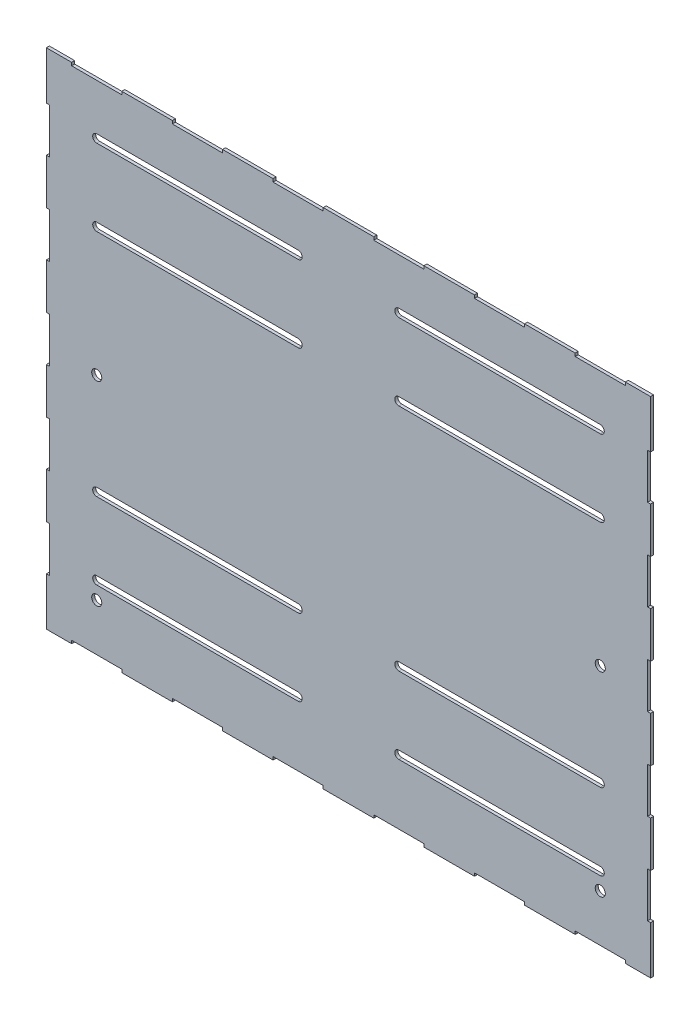
from build123d import *

# Parameters (mm, degrees)
CROQUIS1_W              = 600
CROQUIS1_H              = 500
CROQUIS1_R              = 5
SALIENTE_EXTRUIR1_DEPTH = 3
CROQUIS5_W              = 49.8
CROQUIS5_H              = 3
CROQUIS5_W_2            = 3
CROQUIS5_H_2            = 44.8
CORTAR_EXTRUIR2_DEPTH   = 4


with BuildPart() as part:
    # Croquis1 → Saliente-Extruir1 (new body)
    with BuildSketch(Plane.XY):
        Rectangle(CROQUIS1_W, CROQUIS1_H)
        with Locations((-250, -200)):
            Circle(CROQUIS1_R, mode=Mode.SUBTRACT)
        with Locations((-250, -6.5)):
            Circle(CROQUIS1_R, mode=Mode.SUBTRACT)
        with Locations((250, -200)):
            Circle(CROQUIS1_R, mode=Mode.SUBTRACT)
        with Locations((250, -6.5)):
            Circle(CROQUIS1_R, mode=Mode.SUBTRACT)
        with BuildLine():
            Line((-250, 201), (-50, 201))
            ThreePointArc((-50, 201), (-46, 197), (-50, 193))
            Line((-50, 193), (-250, 193))
            ThreePointArc((-250, 193), (-254, 197), (-250, 201))
        make_face(mode=Mode.SUBTRACT)
        with BuildLine():
            Line((-250, 117), (-50, 117))
            ThreePointArc((-50, 117), (-46, 121), (-50, 125))
            Line((-50, 125), (-250, 125))
            ThreePointArc((-250, 125), (-254, 121), (-250, 117))
        make_face(mode=Mode.SUBTRACT)
        with BuildLine():
            Line((-250, -111), (-50, -111))
            ThreePointArc((-50, -111), (-46, -107), (-50, -103))
            Line((-50, -103), (-250, -103))
            ThreePointArc((-250, -103), (-254, -107), (-250, -111))
        make_face(mode=Mode.SUBTRACT)
        with BuildLine():
            Line((-250, -187), (-50, -187))
            ThreePointArc((-50, -187), (-46, -183), (-50, -179))
            Line((-50, -179), (-250, -179))
            ThreePointArc((-250, -179), (-254, -183), (-250, -187))
        make_face(mode=Mode.SUBTRACT)
        with BuildLine():
            Line((250, -103), (50, -103))
            ThreePointArc((50, -103), (46, -107), (50, -111))
            Line((50, -111), (250, -111))
            ThreePointArc((250, -111), (254, -107), (250, -103))
        make_face(mode=Mode.SUBTRACT)
        with BuildLine():
            Line((250, -179), (50, -179))
            ThreePointArc((50, -179), (46, -183), (50, -187))
            Line((50, -187), (250, -187))
            ThreePointArc((250, -187), (254, -183), (250, -179))
        make_face(mode=Mode.SUBTRACT)
        with BuildLine():
            Line((250, 201), (50, 201))
            ThreePointArc((50, 201), (46, 197), (50, 193))
            Line((50, 193), (250, 193))
            ThreePointArc((250, 193), (254, 197), (250, 201))
        make_face(mode=Mode.SUBTRACT)
        with BuildLine():
            Line((250, 125), (50, 125))
            ThreePointArc((50, 125), (46, 121), (50, 117))
            Line((50, 117), (250, 117))
            ThreePointArc((250, 117), (254, 121), (250, 125))
        make_face(mode=Mode.SUBTRACT)
    extrude(amount=SALIENTE_EXTRUIR1_DEPTH)

    # Croquis5 → Cortar-Extruir2 (cut, through all)
    with BuildSketch(Plane(origin=(0, 0, 0), x_dir=(-1, 0, 0), z_dir=(0, 0, -1))):
        with Locations((150, 248.5)):
            Rectangle(CROQUIS5_W, CROQUIS5_H)
        with Locations((50, 248.5)):
            Rectangle(CROQUIS5_W, CROQUIS5_H)
        with Locations((250, 248.5)):
            Rectangle(CROQUIS5_W, CROQUIS5_H)
        with Locations((-50, 248.5)):
            Rectangle(CROQUIS5_W, CROQUIS5_H)
        with Locations((-150, 248.5)):
            Rectangle(CROQUIS5_W, CROQUIS5_H)
        with Locations((298.5, 180)):
            Rectangle(CROQUIS5_W_2, CROQUIS5_H_2)
        with Locations((-250, 248.5)):
            Rectangle(CROQUIS5_W, CROQUIS5_H)
        with Locations((298.5, 90)):
            Rectangle(CROQUIS5_W_2, CROQUIS5_H_2)
        with Locations((298.5, 0)):
            Rectangle(CROQUIS5_W_2, CROQUIS5_H_2)
        with Locations((298.5, -90)):
            Rectangle(CROQUIS5_W_2, CROQUIS5_H_2)
        with Locations((298.5, -180)):
            Rectangle(CROQUIS5_W_2, CROQUIS5_H_2)
        with Locations((-250, -248.5)):
            Rectangle(CROQUIS5_W, CROQUIS5_H)
        with Locations((-150, -248.5)):
            Rectangle(CROQUIS5_W, CROQUIS5_H)
        with Locations((-50, -248.5)):
            Rectangle(CROQUIS5_W, CROQUIS5_H)
        with Locations((50, -248.5)):
            Rectangle(CROQUIS5_W, CROQUIS5_H)
        with Locations((250, -248.5)):
            Rectangle(CROQUIS5_W, CROQUIS5_H)
        with Locations((150, -248.5)):
            Rectangle(CROQUIS5_W, CROQUIS5_H)
        with Locations((-298.5, -180)):
            Rectangle(CROQUIS5_W_2, CROQUIS5_H_2)
        with Locations((-298.5, -90)):
            Rectangle(CROQUIS5_W_2, CROQUIS5_H_2)
        with Locations((-298.5, 0)):
            Rectangle(CROQUIS5_W_2, CROQUIS5_H_2)
        with Locations((-298.5, 90)):
            Rectangle(CROQUIS5_W_2, CROQUIS5_H_2)
        with Locations((-298.5, 180)):
            Rectangle(CROQUIS5_W_2, CROQUIS5_H_2)
    extrude(amount=-CORTAR_EXTRUIR2_DEPTH, mode=Mode.SUBTRACT)


solid = part.part
